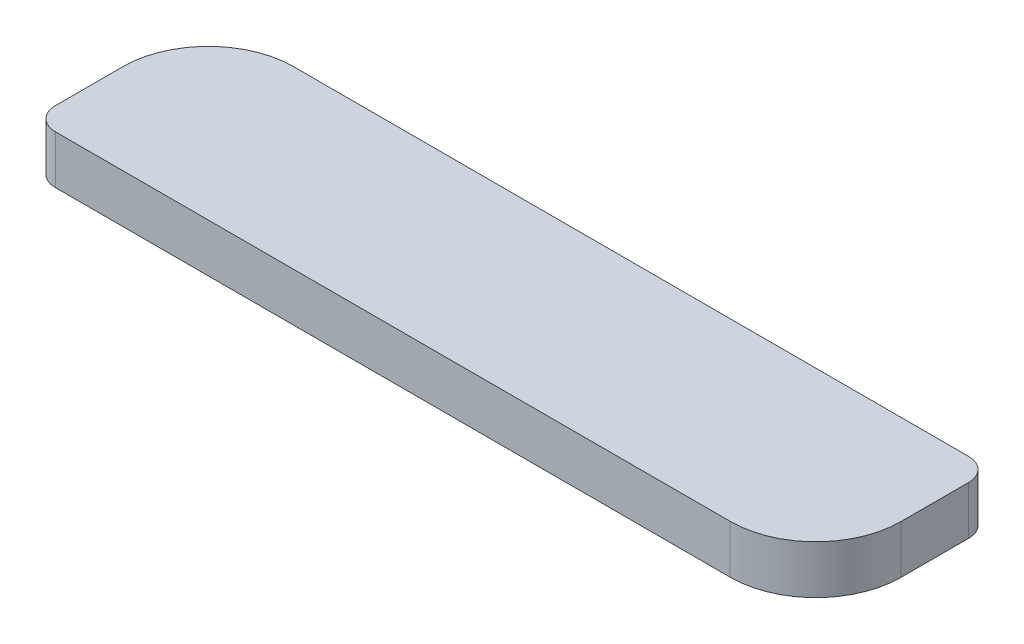
from build123d import *

# Parameters (mm, degrees)
BOSS_EXTRUDE2_DEPTH = 21.5
BOSS_EXTRUDE3_DEPTH = 266


with BuildPart() as part:
    # Sketch1 → Boss-Extrude2 (new body)
    with BuildSketch(Plane(origin=(0, 0, 0), x_dir=(1, 0, 0), z_dir=(0, 1, 0))):
        with BuildLine():
            Line((0, 0), (300, 0))
            ThreePointArc((300, 0), (326.870057685, 11.129942315), (338, 38))
            Line((338, 38), (338, 68))
            ThreePointArc((338, 68), (335.071067812, 75.071067812), (328, 78))
            Line((328, 78), (28, 78))
            ThreePointArc((28, 78), (1.129942315, 66.870057685), (-10, 40))
            Line((-10, 40), (-10, 10))
            ThreePointArc((-10, 10), (-7.071067812, 2.928932188), (0, 0))
        make_face()
    extrude(amount=BOSS_EXTRUDE2_DEPTH)

    # Sketch5 → Boss-Extrude3 (add)
    with BuildSketch(Plane(origin=(28, 0, 0), x_dir=(0, 0, -1), z_dir=(1, 0, 0))):
        with BuildLine():
            Line((78, 0), (42, 0))
            Line((42, 0), (42, -8.17))
            Line((42, -8.17), (44.828427125, -10.998427125))
            Line((44.828427125, -10.998427125), (47.658427125, -10.998427125))
            ThreePointArc((47.658427125, -10.998427125), (60, -0.482256494), (72.341572875, -10.998427125))
            Line((72.341572875, -10.998427125), (75.171572875, -10.998427125))
            Line((75.171572875, -10.998427125), (78, -8.17))
            Line((78, -8.17), (78, 0))
        make_face()
    extrude(amount=BOSS_EXTRUDE3_DEPTH)


solid = part.part
